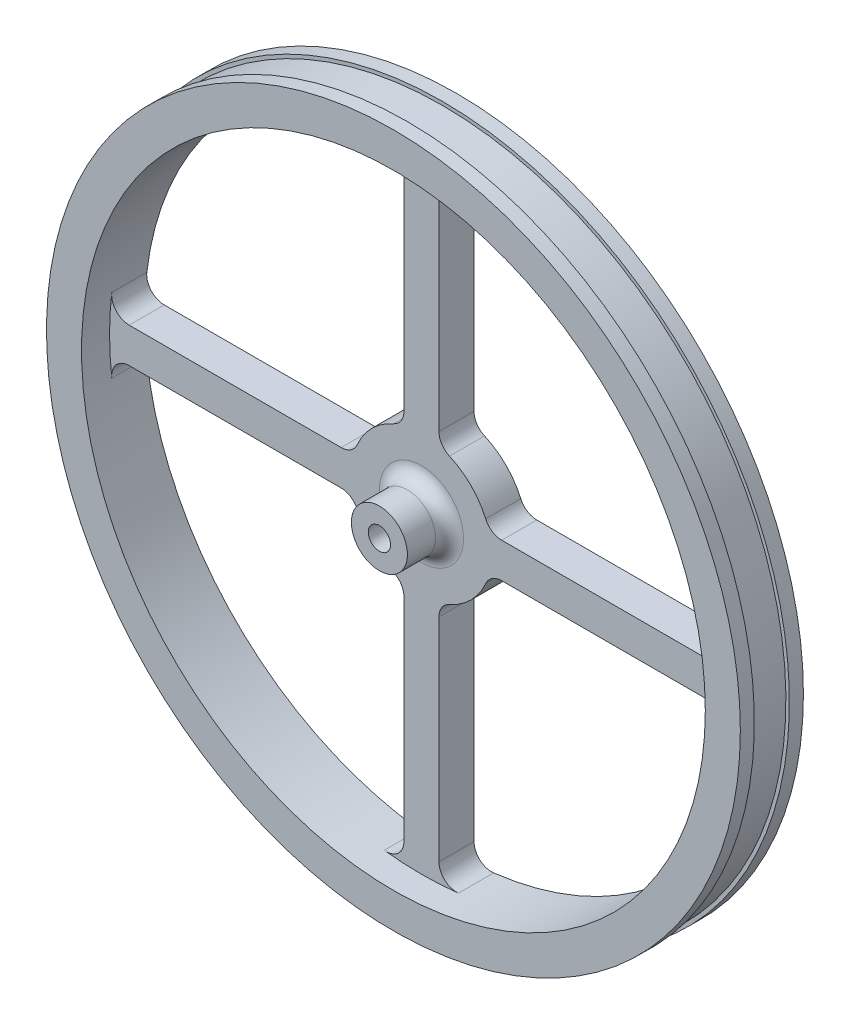
from build123d import *

# Parameters (mm, degrees)
SKETCH1_R           = 49.5
SKETCH1_R_2         = 1.5875
BOSS_EXTRUDE1_DEPTH = 9
CUT_EXTRUDE1_DEPTH  = 10
SKETCH3_R           = 44.5
SKETCH3_R_2         = 4
CUT_EXTRUDE2_DEPTH  = 4
SKETCH4_R           = 4
SKETCH4_R_2         = 1.5875
BOSS_EXTRUDE2_DEPTH = 2
FILLET1_R           = 2
SKETCH5_W           = 5
SKETCH5_H           = 0.5


with BuildPart() as part:
    # Sketch1 → Boss-Extrude1 (new body)
    with BuildSketch(Plane.XY):
        Circle(SKETCH1_R)
        Circle(SKETCH1_R_2, mode=Mode.SUBTRACT)
    extrude(amount=BOSS_EXTRUDE1_DEPTH)

    # Sketch2 → Cut-Extrude1 (cut, through all)
    with BuildSketch(Plane.XY.offset(9)):
        with BuildLine():
            Line((2.5, 11.456439237), (2.5, 41.701318924))
            ThreePointArc((2.5, 41.701318924), (3.340790492, 43.571352028), (5.297619048, 44.183540289))
            ThreePointArc((5.297619048, 44.183540289), (31.466251763, 31.466251763), (44.183540289, 5.297619048))
            ThreePointArc((44.183540289, 5.297619048), (43.571352028, 3.340790492), (41.701318924, 2.5))
            Line((41.701318924, 2.5), (11.456439237, 2.5))
            ThreePointArc((11.456439237, 2.5), (10.087132844, 2.908349934), (9.16515139, 4))
            ThreePointArc((9.16515139, 4), (7.071067812, 7.071067812), (4, 9.16515139))
            ThreePointArc((4, 9.16515139), (2.908349934, 10.087132844), (2.5, 11.456439237))
        make_face()
        with BuildLine():
            Line((-11.456439237, 2.5), (-41.701318924, 2.5))
            ThreePointArc((-41.701318924, 2.5), (-43.571352028, 3.340790492), (-44.183540289, 5.297619048))
            ThreePointArc((-44.183540289, 5.297619048), (-31.466251763, 31.466251763), (-5.297619048, 44.183540289))
            ThreePointArc((-5.297619048, 44.183540289), (-3.340790492, 43.571352028), (-2.5, 41.701318924))
            Line((-2.5, 41.701318924), (-2.5, 11.456439237))
            ThreePointArc((-2.5, 11.456439237), (-2.908349934, 10.087132844), (-4, 9.16515139))
            ThreePointArc((-4, 9.16515139), (-7.071067812, 7.071067812), (-9.16515139, 4))
            ThreePointArc((-9.16515139, 4), (-10.087132844, 2.908349934), (-11.456439237, 2.5))
        make_face()
        with BuildLine():
            Line((-2.5, -11.456439237), (-2.5, -41.701318924))
            ThreePointArc((-2.5, -41.701318924), (-3.340790492, -43.571352028), (-5.297619048, -44.183540289))
            ThreePointArc((-5.297619048, -44.183540289), (-31.466251763, -31.466251763), (-44.183540289, -5.297619048))
            ThreePointArc((-44.183540289, -5.297619048), (-43.571352028, -3.340790492), (-41.701318924, -2.5))
            Line((-41.701318924, -2.5), (-11.456439237, -2.5))
            ThreePointArc((-11.456439237, -2.5), (-10.087132844, -2.908349934), (-9.16515139, -4))
            ThreePointArc((-9.16515139, -4), (-7.071067812, -7.071067812), (-4, -9.16515139))
            ThreePointArc((-4, -9.16515139), (-2.908349934, -10.087132844), (-2.5, -11.456439237))
        make_face()
        with BuildLine():
            Line((11.456439237, -2.5), (41.701318924, -2.5))
            ThreePointArc((41.701318924, -2.5), (43.571352028, -3.340790492), (44.183540289, -5.297619048))
            ThreePointArc((44.183540289, -5.297619048), (31.466251763, -31.466251763), (5.297619048, -44.183540289))
            ThreePointArc((5.297619048, -44.183540289), (3.340790492, -43.571352028), (2.5, -41.701318924))
            Line((2.5, -41.701318924), (2.5, -11.456439237))
            ThreePointArc((2.5, -11.456439237), (2.908349934, -10.087132844), (4, -9.16515139))
            ThreePointArc((4, -9.16515139), (7.071067812, -7.071067812), (9.16515139, -4))
            ThreePointArc((9.16515139, -4), (10.087132844, -2.908349934), (11.456439237, -2.5))
        make_face()
    extrude(amount=-CUT_EXTRUDE1_DEPTH, mode=Mode.SUBTRACT)

    # Sketch3 → Cut-Extrude2 (cut)
    with BuildSketch(Plane.XY.offset(9)):
        Circle(SKETCH3_R)
        Circle(SKETCH3_R_2, mode=Mode.SUBTRACT)
    extrude(amount=-CUT_EXTRUDE2_DEPTH, mode=Mode.SUBTRACT)

    # Sketch4 → Boss-Extrude2 (add)
    with BuildSketch(Plane.XY.offset(9)):
        Circle(SKETCH4_R)
        Circle(SKETCH4_R_2, mode=Mode.SUBTRACT)
    extrude(amount=BOSS_EXTRUDE2_DEPTH)

    # Fillet1
    fillet1_edges = [part.edges().sort_by_distance(p)[0] for p in [
        (-4, 0, 5),
    ]]
    fillet(fillet1_edges, radius=FILLET1_R)

    # Sketch5 → Cut-Revolve1 (revolve, cut)
    with BuildSketch(Plane(origin=(0, 0, 0), x_dir=(0, 0, -1), z_dir=(1, 0, 0))):
        with Locations((-4.5, 49.25)):
            Rectangle(SKETCH5_W, SKETCH5_H)
    revolve(axis=Axis((0, 0, 0), (0, 0, 1)), mode=Mode.SUBTRACT)


solid = part.part
